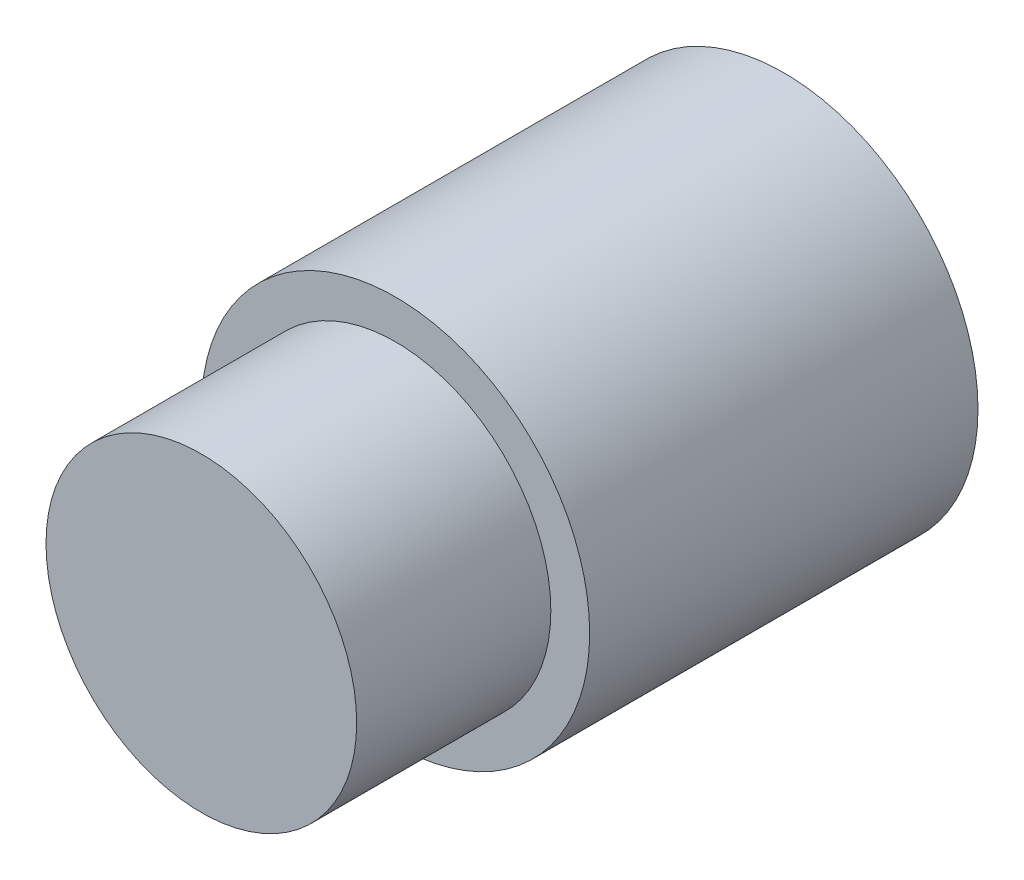
from build123d import *

# Parameters (mm, degrees)
SKETCH_1_R          = 10
EXTRUDE_1_DEPTH     = 20
SKETCH_2_R          = 1.5
CUT_EXTRUDE_1_DEPTH = 10
SKETCH_3_R          = 8
EXTRUDE_2_DEPTH     = 10


with BuildPart() as part:
    # 스케치1 → 보스-돌출1 (new body)
    with BuildSketch(Plane.XY):
        Circle(SKETCH_1_R)
    extrude(amount=EXTRUDE_1_DEPTH)

    # 스케치2 → 컷-돌출1 (cut)
    with BuildSketch(Plane(origin=(0, 0, 0), x_dir=(-1, 0, 0), z_dir=(0, 0, -1))):
        Circle(SKETCH_2_R)
    extrude(amount=-CUT_EXTRUDE_1_DEPTH, mode=Mode.SUBTRACT)

    # 스케치3 → 보스-돌출2 (add)
    with BuildSketch(Plane.XY.offset(20)):
        Circle(SKETCH_3_R)
    extrude(amount=EXTRUDE_2_DEPTH)


solid = part.part
